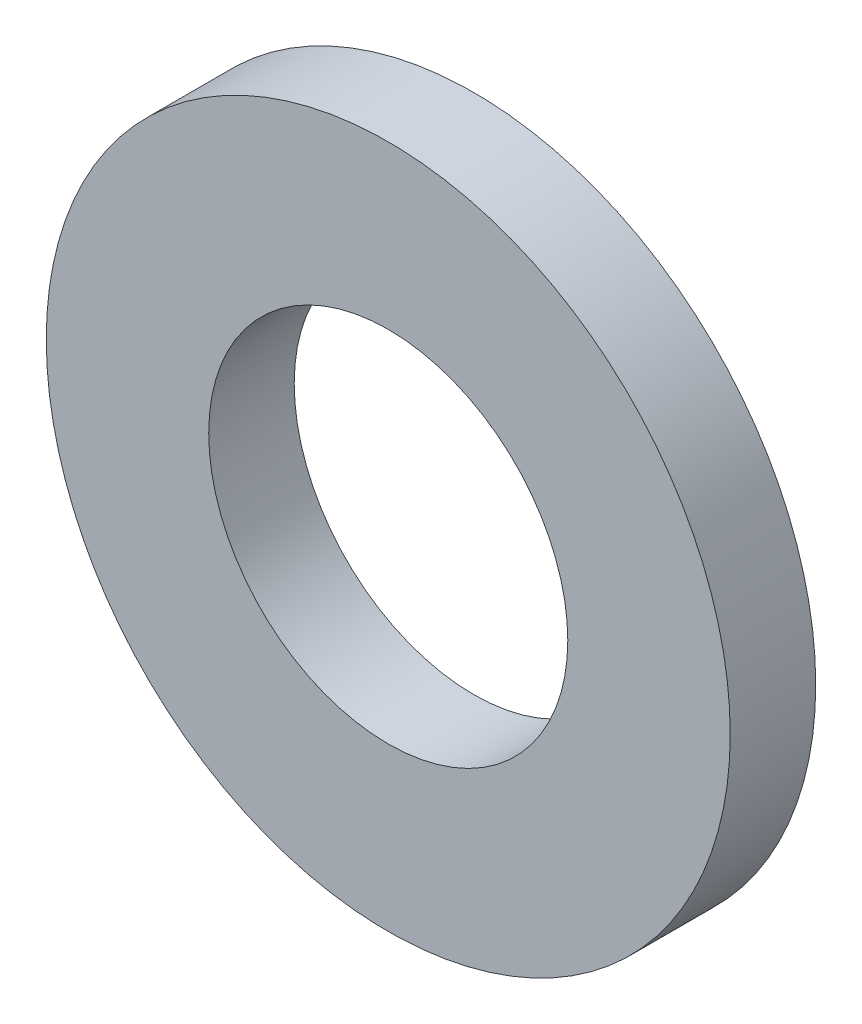
from build123d import *

# Parameters (mm, degrees)
SKETCH3_R           = 2
SKETCH3_R_2         = 1.05
BOSS_EXTRUDE1_DEPTH = 0.25


with BuildPart() as part:
    # Sketch3 → Boss-Extrude1 (new body, symmetric)
    with BuildSketch(Plane.XY):
        Circle(SKETCH3_R)
        Circle(SKETCH3_R_2, mode=Mode.SUBTRACT)
    extrude(amount=BOSS_EXTRUDE1_DEPTH, both=True)


solid = part.part
